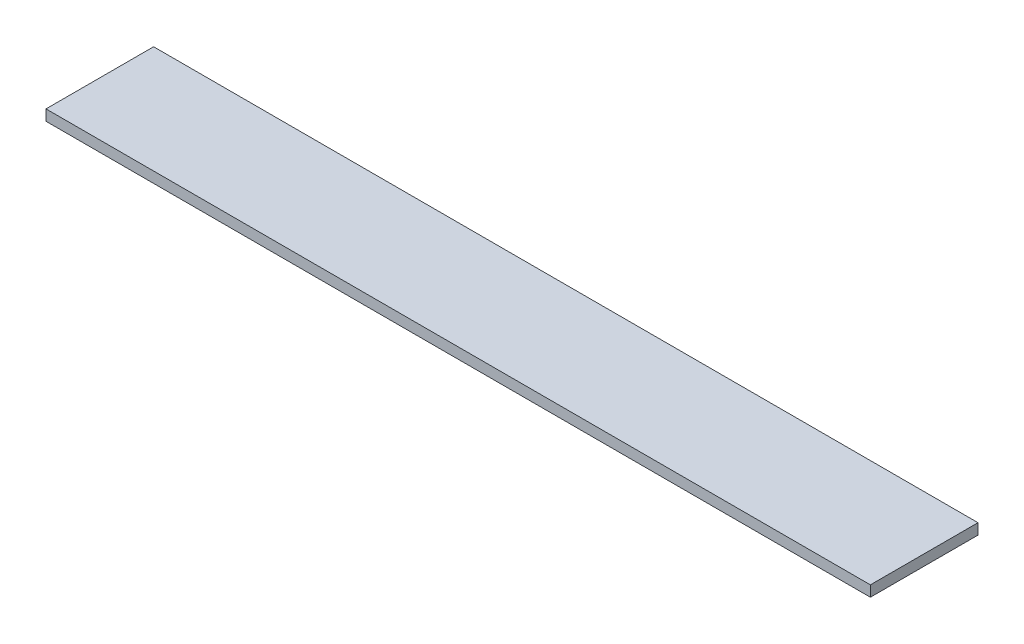
from build123d import *

# Parameters (mm, degrees)
ESQUISSE1_W      = 766
ESQUISSE1_H      = 100
EXTRUSION1_DEPTH = 10


with BuildPart() as part:
    # Esquisse1 → Extrusion1 (new body)
    with BuildSketch(Plane(origin=(0, 0, 0), x_dir=(1, 0, 0), z_dir=(0, 1, 0))):
        with Locations((383, 50)):
            Rectangle(ESQUISSE1_W, ESQUISSE1_H)
    extrude(amount=EXTRUSION1_DEPTH)


solid = part.part
